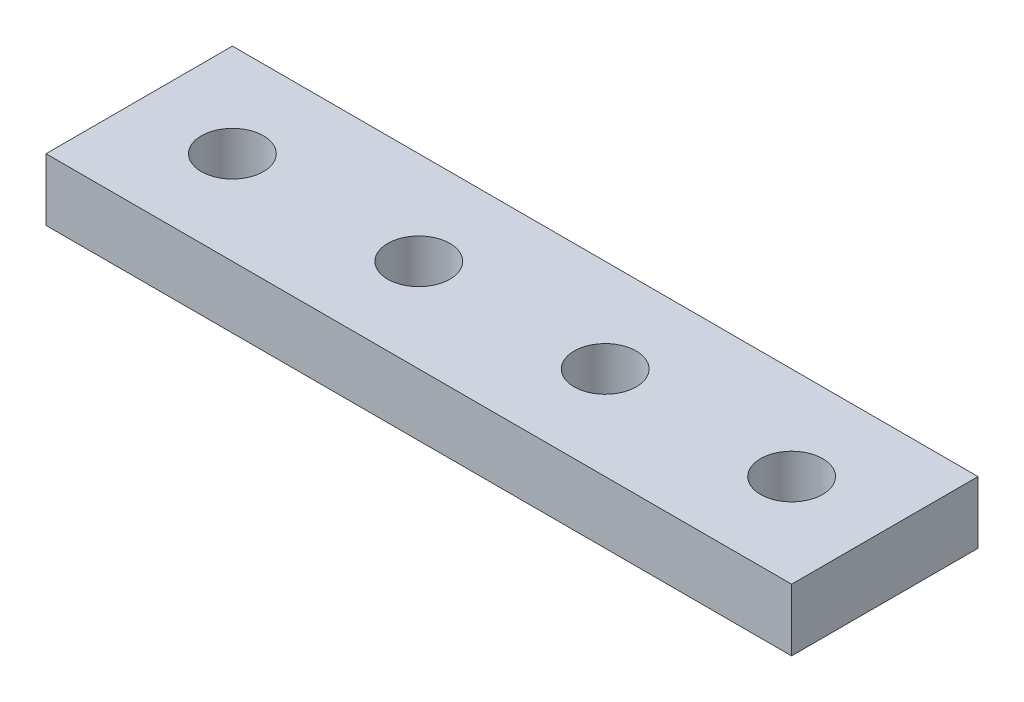
from build123d import *

# Parameters (mm, degrees)
SKETCH1_W            = 120
SKETCH1_H            = 30
BOSS_EXTRUDE1_DEPTH  = 10
SKETCH2_R            = 5
CUT_EXTRUDE1_DEPTH   = 11
LPATTERN1_COUNT      = 4
LPATTERN1_PITCH      = 30
LPATTERN1_COUNT_DIR2 = 4
LPATTERN1_PITCH_DIR2 = 30


with BuildPart() as part:
    # Sketch1 → Boss-Extrude1 (new body)
    with BuildSketch(Plane(origin=(0, 0, 0), x_dir=(1, 0, 0), z_dir=(0, 1, 0))):
        with Locations((60, 15)):
            Rectangle(SKETCH1_W, SKETCH1_H)
    extrude(amount=BOSS_EXTRUDE1_DEPTH)

    # Sketch2 → Cut-Extrude1 (cut, through all)
    with BuildSketch(Plane(origin=(0, 10, 0), x_dir=(1, 0, 0), z_dir=(0, 1, 0))):
        with Locations((15, 15)):
            Circle(SKETCH2_R)
    cut_extrude1 = extrude(amount=-CUT_EXTRUDE1_DEPTH, mode=Mode.SUBTRACT)

    # LPattern1: Cut-Extrude1 4 × 4
    with Locations(*[(i * LPATTERN1_PITCH, 0, j * LPATTERN1_PITCH_DIR2) for i in range(LPATTERN1_COUNT) for j in range(LPATTERN1_COUNT_DIR2) if (i, j) != (0, 0)]):
        add(cut_extrude1, mode=Mode.SUBTRACT)


solid = part.part
